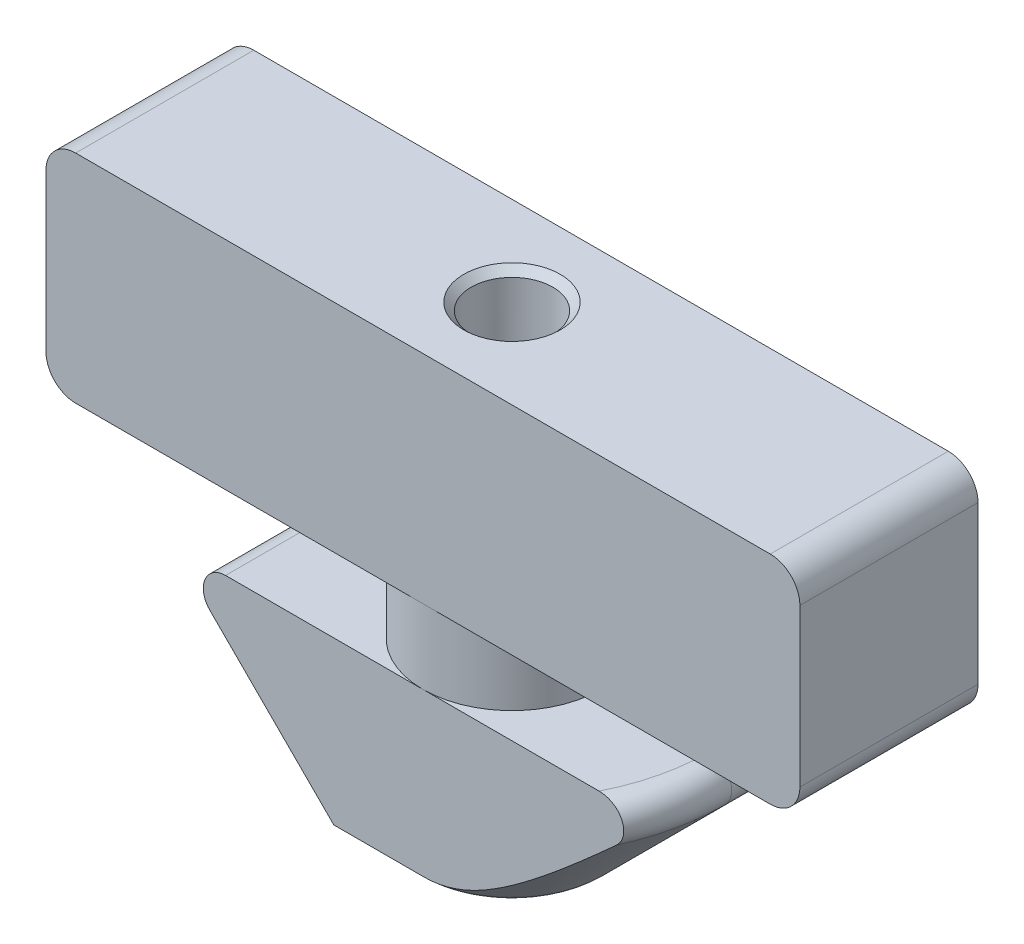
from build123d import *

# Parameters (mm, degrees)
SKETCH1_W               = 25.4
SKETCH1_H               = 7.3
BOSS_EXTRUDE1_DEPTH     = 6
SKETCH3_W               = 4.4
SKETCH3_H               = 5.7
CUT_EXTRUDE1_DEPTH      = 21.24530815
CUT_EXTRUDE1_DEPTH_BACK = 21.24530815
BOSS_EXTRUDE3_START     = -3
BOSS_EXTRUDE3_DEPTH     = 3
BOSS_EXTRUDE4_START     = -3
BOSS_EXTRUDE4_DEPTH     = 3
FILLET1_R               = 1
CUT_EXTRUDE2_DEPTH      = 19.376955775
CUT_EXTRUDE3_DEPTH      = 19.376955775
SKETCH9_R               = 1.375
CUT_EXTRUDE4_DEPTH      = 8
CHAMFER1_SIZE           = 0.25


with BuildPart() as part:
    # Sketch1 → Boss-Extrude1 (new body)
    with BuildSketch(Plane.XY):
        Rectangle(SKETCH1_W, SKETCH1_H)
    extrude(amount=BOSS_EXTRUDE1_DEPTH)

    # Sketch2 → Revolve1 (revolve)
    with BuildSketch(Plane.XY.offset(3), mode=Mode.PRIVATE) as revolve1_sk:
        with BuildLine():
            Line((6.65, -6.15), (3, -6.15))
            Line((3, -6.15), (3, -3.65))
            Line((3, -3.65), (0, -3.65))
            Line((0, -3.65), (0, -11.85))
            Line((0, -11.85), (2.346446609, -11.85))
            ThreePointArc((2.346446609, -11.85), (2.729130042, -11.773879533), (3.053553391, -11.557106781))
            Line((3.053553391, -11.557106781), (7.180330086, -7.430330086))
            ThreePointArc((7.180330086, -7.430330086), (7.342909649, -6.612987426), (6.65, -6.15))
        make_face()
    revolve(revolve1_sk.sketch.rotate(Axis((0, 0, 3), (0, -1, 0)), 180), axis=Axis((0, 0, 3), (0, -1, 0)))

    # Sketch3 → Cut-Extrude1 (cut, two sides)
    with BuildSketch(Plane(origin=(0, 0, 0), x_dir=(0, 0, -1), z_dir=(1, 0, 0))) as cut_extrude1_sk:
        with Locations((-8.2, -9)):
            Rectangle(SKETCH3_W, SKETCH3_H)
        with Locations((2.2, -9)):
            Rectangle(SKETCH3_W, SKETCH3_H)
    extrude(amount=CUT_EXTRUDE1_DEPTH, mode=Mode.SUBTRACT)
    extrude(cut_extrude1_sk.sketch, amount=-CUT_EXTRUDE1_DEPTH_BACK, mode=Mode.SUBTRACT)

    # Sketch5 → Boss-Extrude3 (add)
    with BuildSketch(Plane(origin=(0, 0, 0), x_dir=(-1, 0, 0), z_dir=(0, 0, -1)).offset(BOSS_EXTRUDE3_START)):
        with BuildLine():
            Line((-7.180330086, -7.430330086), (-3.053553391, -11.557106781))
            ThreePointArc((-3.053553391, -11.557106781), (-2.729130042, -11.773879533), (-2.346446609, -11.85))
            Line((-2.346446609, -11.85), (0, -11.85))
            Line((0, -11.85), (0, -6.15))
            Line((0, -6.15), (-6.65, -6.15))
            ThreePointArc((-6.65, -6.15), (-7.342909649, -6.612987426), (-7.180330086, -7.430330086))
        make_face()
    extrude(amount=BOSS_EXTRUDE3_DEPTH)

    # Sketch6 → Boss-Extrude4 (add)
    with BuildSketch(Plane.XY.offset(6).offset(BOSS_EXTRUDE4_START)):
        with BuildLine():
            Line((0, -11.85), (0, -11.606880417))
            add(Edge.make_bspline(
                [(-0.569375368, -11.557106781), (-0.477136244, -11.574305984), (-0.383216001, -11.587587431), (-0.288131205, -11.597299525), (-0.192322641, -11.603685849), (-0.096171282, -11.606880411), (0, -11.606880417)],
                knots=[0, 0, 0, 0, 0, 0, 0, 0.500004034, 0.500004034, 0.500004034, 0.500004034, 0.500004034, 0.500004034, 0.500004034], degree=6))
            add(Edge.make_bspline(
                [(-0.569375368, -11.557106781), (-2.345972894, -11.225836703), (-6.523583382, -7.430330086)],
                knots=[0.188670459, 0.188670459, 0.188670459, 1.519069158, 1.519069158, 1.519069158], degree=2, weights=[1, 1.229524605, 1]))
            add(Edge.make_bspline(
                [(-6.523583382, -7.430330086), (-6.548217839, -7.407948812), (-6.57163623, -7.384387754), (-6.593752622, -7.359710949), (-6.614485917, -7.333990738), (-6.633761234, -7.307307749), (-6.688090057, -7.222962512), (-6.718198081, -7.1624526), (-6.741231365, -7.099013892), (-6.756763407, -7.033555882), (-6.764556488, -6.967070385), (-6.764657168, -6.849785487), (-6.760183262, -6.798976266), (-6.751191088, -6.748616972), (-6.737758143, -6.699153447), (-6.720033498, -6.651010063), (-6.68841653, -6.583676772), (-6.677775298, -6.563121343), (-6.666326858, -6.542947595), (-6.654092776, -6.523189068), (-6.641096757, -6.503877463), (-6.605240936, -6.454697957), (-6.581206245, -6.425590465), (-6.555368287, -6.397845087), (-6.527846234, -6.371572034), (-6.498768133, -6.346867107), (-6.393778747, -6.267504617), (-6.310809109, -6.22103841), (-6.221317835, -6.185601518), (-6.127427397, -6.161840052), (-6.031244011, -6.15), (-5.934854674, -6.15)],
                knots=[0, 0, 0, 0, 0, 0, 0, 0.107806274, 0.107806274, 0.107806274, 0.107806274, 0.107806274, 0.32997016, 0.32997016, 0.32997016, 0.32997016, 0.32997016, 0.499739877, 0.499739877, 0.499739877, 0.499739877, 0.499739877, 0.576163763, 0.576163763, 0.576163763, 0.576163763, 0.576163763, 0.699289859, 0.699289859, 0.699289859, 0.699289859, 0.699289859, 1, 1, 1, 1, 1, 1, 1], degree=6))
            Line((-5.934854674, -6.15), (-6.65, -6.15))
            ThreePointArc((-6.65, -6.15), (-7.342909649, -6.612987426), (-7.180330086, -7.430330086))
            Line((-7.180330086, -7.430330086), (-3.053553391, -11.557106781))
            ThreePointArc((-3.053553391, -11.557106781), (-2.729130042, -11.773879533), (-2.346446609, -11.85))
            Line((-2.346446609, -11.85), (0, -11.85))
        make_face()
    extrude(amount=BOSS_EXTRUDE4_DEPTH)

    # Fillet1
    fillet1_edges = [part.edges().sort_by_distance(p)[0] for p in [
        (12.7, -3.65, 3),
        (-12.7, -3.65, 3),
        (-12.7, 3.65, 3),
        (12.7, 3.65, 3),
    ]]
    fillet(fillet1_edges, radius=FILLET1_R)

    # Sketch7 → Cut-Extrude2 (cut, through all)
    with BuildSketch(Plane.ZY):
        with BuildLine():
            Line((0, -11.606880417), (0, -11.85))
            Line((0, -11.85), (0.653553391, -11.85))
            ThreePointArc((0.653553391, -11.85), (0.304899133, -11.787251412), (0, -11.606880417))
        make_face()
    extrude(amount=-CUT_EXTRUDE2_DEPTH, mode=Mode.SUBTRACT)

    # Sketch8 → Cut-Extrude3 (cut, through all)
    with BuildSketch(Plane(origin=(0, 0, 0), x_dir=(0, 0, -1), z_dir=(1, 0, 0))):
        with BuildLine():
            Line((-6, -11.606880417), (-6, -11.85))
            Line((-6, -11.85), (-5.346446609, -11.85))
            ThreePointArc((-5.346446609, -11.85), (-5.695100867, -11.787251412), (-6, -11.606880417))
        make_face()
    extrude(amount=-CUT_EXTRUDE3_DEPTH, mode=Mode.SUBTRACT)

    # Sketch9 → Cut-Extrude4 (cut)
    with BuildSketch(Plane(origin=(0, 3.65, 0), x_dir=(1, 0, 0), z_dir=(0, 1, 0))):
        with Locations(Location((0, -3, 0), (0, 0, 270))):
            Circle(SKETCH9_R)
    extrude(amount=-CUT_EXTRUDE4_DEPTH, mode=Mode.SUBTRACT)

    # Chamfer1
    chamfer1_edges = [part.edges().sort_by_distance(p)[0] for p in [
        (0, 3.65, 1.625),
    ]]
    chamfer(chamfer1_edges, length=CHAMFER1_SIZE)


solid = part.part
